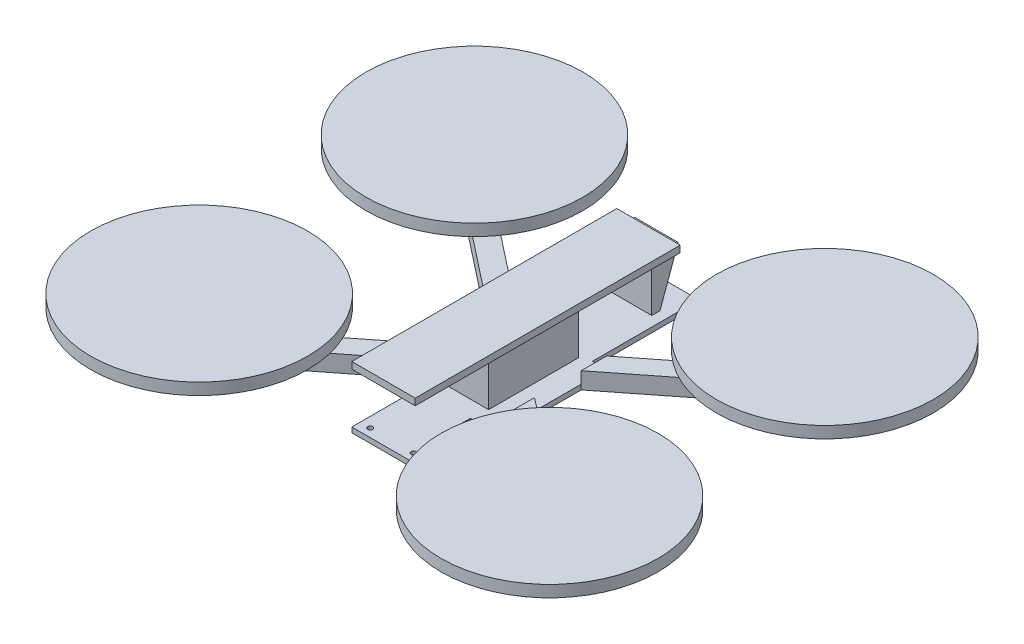
from build123d import *

# Parameters (mm, degrees)
SKETCH2_W           = 38
SKETCH2_H           = 170
SKETCH2_R           = 1.5
SKETCH2_W_2         = 2
SKETCH2_H_2         = 6
SKETCH2_W_3         = 55
SKETCH2_H_3         = 58.475280412
BOSS_EXTRUDE2_DEPTH = 3
BOSS_EXTRUDE3_DEPTH = 10
SKETCH2_4_R         = 15
BOSS_EXTRUDE4_DEPTH = 25
SKETCH3_R           = 65
BOSS_EXTRUDE5_DEPTH = 7
SKETCH4_W           = 26
SKETCH4_H           = 54
SKETCH4_H_2         = 15.857774488
BOSS_EXTRUDE6_DEPTH = 30
SKETCH5_W           = 38
SKETCH5_H           = 158.814442682
BOSS_EXTRUDE7_DEPTH = 4
DRAFT1_ANGLE        = -20
SKETCH6_R           = 0.5
CUT_EXTRUDE1_DEPTH  = 1


with BuildPart() as part:
    # Sketch2 → Boss-Extrude2 (new body)
    with BuildSketch(Plane(origin=(0, 0, 0), x_dir=(1, 0, 0), z_dir=(0, 1, 0))):
        with Locations((0, 8)):
            Rectangle(SKETCH2_W, SKETCH2_H)
        with Locations((-13, -72)):
            Circle(SKETCH2_R, mode=Mode.SUBTRACT)
        with Locations((13, -72)):
            Circle(SKETCH2_R, mode=Mode.SUBTRACT)
        with Locations((13, -40)):
            Rectangle(SKETCH2_W_2, SKETCH2_H_2, mode=Mode.SUBTRACT)
        with Locations((-13.416960254, -40)):
            Rectangle(SKETCH2_W_2, SKETCH2_H_2, mode=Mode.SUBTRACT)
        Rectangle(SKETCH2_W_3, SKETCH2_H_3)
        with Locations((-25.5, 20)):
            Circle(SKETCH2_R, mode=Mode.SUBTRACT)
        with Locations((25.5, 20)):
            Circle(SKETCH2_R, mode=Mode.SUBTRACT)
        with Locations((25.5, -20)):
            Circle(SKETCH2_R, mode=Mode.SUBTRACT)
        with Locations((-25.5, -20)):
            Circle(SKETCH2_R, mode=Mode.SUBTRACT)
    extrude(amount=BOSS_EXTRUDE2_DEPTH)

    # Sketch2_3 → Boss-Extrude3 (add)
    with BuildSketch(Plane(origin=(0, 0, 0), x_dir=(1, 0, 0), z_dir=(0, 1, 0))):
        with BuildLine():
            ThreePointArc((-90.482980764, 78.72426795), (-93.205224918, 73.232676721), (-97.896839388, 69.288447884))
            Line((-97.896839388, 69.288447884), (-27.5, 13.976645508))
            Line((-27.5, 13.976645508), (-27.5, 29.237640206))
            Line((-27.5, 29.237640206), (-90.482980764, 78.72426795))
        make_face()
        with BuildLine():
            Line((-27.5, -13.976645508), (-97.896839388, -69.288447884))
            ThreePointArc((-97.896839388, -69.288447884), (-93.205224918, -73.232676721), (-90.482980764, -78.72426795))
            Line((-90.482980764, -78.72426795), (-27.5, -29.237640206))
            Line((-27.5, -29.237640206), (-27.5, -13.976645508))
        make_face()
        with BuildLine():
            Line((90.482980764, 78.72426795), (27.5, 29.237640206))
            Line((27.5, 29.237640206), (27.5, 13.976645508))
            Line((27.5, 13.976645508), (97.896839388, 69.288447884))
            ThreePointArc((97.896839388, 69.288447884), (93.205224918, 73.232676721), (90.482980764, 78.72426795))
        make_face()
        with BuildLine():
            Line((27.5, -29.237640206), (90.482980764, -78.72426795))
            ThreePointArc((90.482980764, -78.72426795), (93.205224918, -73.232676721), (97.896839388, -69.288447884))
            Line((97.896839388, -69.288447884), (27.5, -13.976645508))
            Line((27.5, -13.976645508), (27.5, -29.237640206))
        make_face()
    extrude(amount=BOSS_EXTRUDE3_DEPTH)

    # Sketch2_4 → Boss-Extrude4 (add)
    with BuildSketch(Plane(origin=(0, 0, 0), x_dir=(1, 0, 0), z_dir=(0, 1, 0))):
        with Locations((-105, 82.5)):
            Circle(SKETCH2_4_R)
        with Locations((105, 82.5)):
            Circle(SKETCH2_4_R)
        with Locations((105, -82.5)):
            Circle(SKETCH2_4_R)
        with Locations((-105, -82.5)):
            Circle(SKETCH2_4_R)
    extrude(amount=BOSS_EXTRUDE4_DEPTH)

    # Sketch3 → Boss-Extrude5 (add)
    with BuildSketch(Plane(origin=(0, 25, 0), x_dir=(1, 0, 0), z_dir=(0, 1, 0))):
        with Locations((-105, -82.5)):
            Circle(SKETCH3_R)
        with Locations((105, -82.5)):
            Circle(SKETCH3_R)
        with Locations((105, 82.5)):
            Circle(SKETCH3_R)
        with Locations((-105, 82.5)):
            Circle(SKETCH3_R)
    extrude(amount=BOSS_EXTRUDE5_DEPTH)

    # Sketch4 → Boss-Extrude6 (add)
    with BuildSketch(Plane(origin=(0, 3, 0), x_dir=(1, 0, 0), z_dir=(0, 1, 0))):
        Rectangle(SKETCH4_W, SKETCH4_H)
        with Locations((0, 78.679384084)):
            Rectangle(SKETCH4_W, SKETCH4_H_2)
    extrude(amount=BOSS_EXTRUDE6_DEPTH)

    # Sketch5 → Boss-Extrude7 (add)
    with BuildSketch(Plane(origin=(0, 33, 0), x_dir=(1, 0, 0), z_dir=(0, 1, 0))):
        with Locations((0, 2.407221341)):
            Rectangle(SKETCH5_W, SKETCH5_H)
    extrude(amount=BOSS_EXTRUDE7_DEPTH)

    # Draft1
    draft1_faces = [part.faces().sort_by_distance(p)[0] for p in [
        (0, 18, -86.608271328),
    ]]
    draft(draft1_faces, Plane.ZX.offset(33), DRAFT1_ANGLE)

    # Sketch6 → Cut-Extrude1 (cut)
    with BuildSketch(Plane.XZ):
        Circle(SKETCH6_R)
    extrude(amount=-CUT_EXTRUDE1_DEPTH, mode=Mode.SUBTRACT)


solid = part.part
